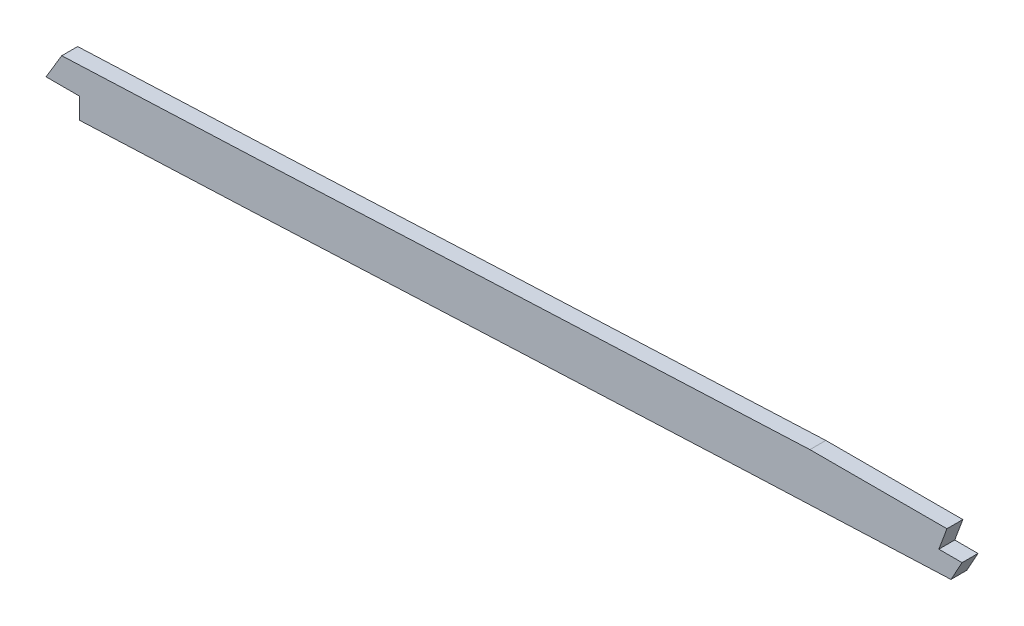
from build123d import *

# Parameters (mm, degrees)
BOSS_EXTRUDE1_DEPTH = 3.175
CUT_EXTRUDE1_DEPTH  = 7.3500001
FILLET1_R           = 2.54
CUT_EXTRUDE2_DEPTH  = 7.62


with BuildPart() as part:
    # Sketch1 → Boss-Extrude1 (new body, symmetric)
    with BuildSketch(Plane.XY):
        with BuildLine():
            Line((499.61002795, -53.470702797), (1046.28548189, -53.470702797))
            add(Edge.make_bspline(
                [(2669.54, -9.569049356), (2615.393603553, -13.17073937), (2561.080658619, -16.536108081), (2506.205230446, -19.758621957), (2430.209106802, -23.505211705), (2354.212983157, -26.631486423), (2332.570330468, -27.480988169), (2156.268639429, -34.377768543), (1979.966947376, -41.628631248), (1824.114277635, -52.771265877), (1636.928606778, -53.579569849), (1449.742935921, -53.454024613), (1418.006730935, -53.470702797), (1324.899336146, -53.470702797), (1231.791940344, -53.470702797), (1170.441269319, -53.470702797), (1108.784075813, -53.470702797), (1047.126882346, -53.470702797), (1046.846414188, -53.470702797), (1046.565947184, -53.470702797), (1046.28548189, -53.470702797)],
                knots=[103.698913506, 103.698913506, 103.698913506, 103.698913506, 103.698913506, 103.698913506, 130.927896619, 130.927896619, 130.927896619, 141.337054719, 141.337054719, 141.337054719, 218.101815019, 218.101815019, 218.101815019, 233.772059419, 233.772059419, 233.772059419, 264.077723219, 264.077723219, 264.077723219, 264.2162088, 264.2162088, 264.2162088, 264.2162088, 264.2162088, 264.2162088], degree=5))
            Line((2669.54, -9.569049356), (2669.54, 9.5231025))
            add(Edge.make_bspline(
                [(2669.54, 9.5231025), (2667.126494524, 9.36235515), (2659.861586685, 8.880281494), (2635.666282302, 7.292469146), (2596.857665529, 4.826056853), (2545.729743039, 1.758344093), (2494.405305707, -1.098555235), (2451.533022267, -3.266573297), (2417.198316756, -4.86708361), (2391.457076919, -6.003589235), (2365.634736307, -7.086854581), (2339.546284672, -8.137729944), (2313.466132974, -9.165138371), (2287.612375486, -10.179478215), (2261.763347437, -11.201032297), (2227.285329715, -12.583842557), (2184.175569393, -14.36607236), (2132.429066114, -16.607427868), (2063.4255234, -19.708920485), (1977.174907635, -23.700543313), (1873.732451432, -28.149389221), (1770.37461881, -31.657468649), (1667.085687813, -33.793117556), (1581.011094491, -34.383188831), (1512.07397126, -34.4278026), (1443.061513477, -34.409510402), (1356.800927879, -34.424432812), (1218.794626954, -34.418464788), (1115.289022786, -34.420702797), (1046.28548189, -34.420702797)],
                knots=[103.571582669, 103.571582669, 103.571582669, 103.571582669, 104.300777207, 105.766098403, 110.877392287, 115.98868617, 121.099980054, 126.211273938, 128.76692088, 131.322567822, 133.878214764, 136.433861706, 138.989508647, 141.545155589, 144.100802531, 146.656449473, 151.767743357, 156.879037241, 161.990331124, 172.212918892, 182.43550666, 192.658094427, 202.880682195, 213.103269962, 218.214563846, 223.32585773, 233.548445497, 243.771033265, 264.2162088, 264.2162088, 264.2162088, 264.2162088], degree=3))
            Line((1046.28548189, -34.420702797), (499.61002795, -34.420702797))
            add(Edge.make_bspline(
                [(499.61002795, -34.420702797), (488.614737518, -34.420702797), (472.236395365, -34.420702798), (449.940231846, -34.420702794), (427.771305695, -34.42070281), (405.874681663, -34.420702712), (384.584909128, -34.420702942), (368.900229326, -34.420702244), (353.376568613, -34.420704862), (332.608466435, -34.420689186), (306.287754853, -34.420570006), (274.023487704, -34.420538256), (252.271015965, -34.420709741), (241.425150134, -34.420702761)],
                knots=[19.90682951, 19.90682951, 19.90682951, 19.90682951, 23.220120017, 24.876765271, 26.533410525, 29.846701033, 31.503346286, 33.15999154, 34.816636794, 36.473282048, 39.786572556, 43.099863063, 46.413153571, 46.413153571, 46.413153571, 46.413153571], degree=3))
            add(Edge.make_bspline(
                [(241.425150134, -34.420702761), (239.394928853, -34.420701455), (235.322322927, -34.420495867), (227.274423443, -34.398702533), (217.319360062, -34.297466855), (205.530690077, -33.976385563), (189.963341914, -33.212641271), (170.696984653, -31.543495194), (147.533261232, -28.314398128), (125.482753206, -24.202109872), (109.358914834, -20.622537553), (100.964116069, -18.612521054), (99.06, -18.149327722)],
                knots=[0, 0, 0, 0, 0.622088422, 1.244176844, 2.488353689, 3.732530533, 4.976707377, 7.465061066, 9.953414755, 12.441768444, 14.55823542, 15.180323842, 15.180323842, 15.180323842, 15.180323842], degree=3))
            Line((99.06, -18.149327722), (99.06, -37.741485304))
            add(Edge.make_bspline(
                [(241.425137875, -53.470702761), (224.286916993, -53.470691732), (207.149474967, -53.467315374), (190.203897513, -52.686577078), (161.734965878, -49.987457476), (133.266034188, -45.175583375), (121.749620566, -42.910592695), (110.349390726, -40.420274627), (99.06, -37.741485304)],
                knots=[0, 0, 0, 0, 0, 0, 8.71381608, 8.71381608, 8.71381608, 14.701907176, 14.701907176, 14.701907176, 14.701907176, 14.701907176, 14.701907176], degree=5))
            add(Edge.make_bspline(
                [(499.61002795, -53.470702797), (492.136820835, -53.470702797), (484.754348064, -53.470702797), (477.443025859, -53.470702797), (448.516583145, -53.470702797), (419.590140517, -53.470702797), (398.368118521, -53.470702797), (355.647540186, -53.470702797), (312.926961851, -53.470702797), (289.235090436, -53.470293029), (265.364963651, -53.470705034), (241.4948369, -53.470702789), (241.471603891, -53.470702785), (241.448370882, -53.470702776), (241.425137875, -53.470702761)],
                knots=[19.90682951, 19.90682951, 19.90682951, 19.90682951, 19.90682951, 19.90682951, 23.637897311, 23.637897311, 23.637897311, 34.276545571, 34.276545571, 34.276545571, 46.401340901, 46.401340901, 46.401340901, 46.413153571, 46.413153571, 46.413153571, 46.413153571, 46.413153571, 46.413153571], degree=5))
        make_face()
    extrude(amount=BOSS_EXTRUDE1_DEPTH, both=True)

    # Sketch2 → Cut-Extrude1 (cut, through all)
    with BuildSketch(Plane.XY.offset(3.175)):
        with BuildLine():
            add(Edge.make_bspline(
                [(2312.9875, -9.183260037), (2304.505441691, -9.516700376), (2287.441020622, -10.186250162), (2261.763347437, -11.201032297), (2228.230552004, -12.545932515), (2203.310445107, -13.575047161), (2187.00995947, -14.263260037)],
                knots=[139.04033329, 139.04033329, 139.04033329, 139.04033329, 141.545155589, 144.100802531, 146.656449473, 151.487488909, 151.487488909, 151.487488909, 151.487488909], degree=3))
            Line((2187.00995947, -14.263260037), (2312.9875, -14.263260037))
            Line((2312.9875, -14.263260037), (2312.9875, -9.183260037))
        make_face()
    extrude(amount=-CUT_EXTRUDE1_DEPTH, mode=Mode.SUBTRACT)

    # Fillet1
    fillet1_edges = [part.edges().sort_by_distance(p)[0] for p in [
        (2669.54, -9.569049356, -1.5875),
        (2669.54, 9.5231025, -1.5875),
        (99.06, -37.741485304, -1.5875),
        (99.06, -18.149327722, -1.5875),
        (2312.9875, -9.183260037, 1.5875),
        (2312.9875, -14.263260037, 0),
    ]]
    fillet(fillet1_edges, radius=FILLET1_R)

    # Sketch3 → Cut-Extrude2 (cut)
    with BuildSketch(Plane.XY.offset(3.175)):
        Polygon((1888.274985361, -27.424617015), (1881.98614013, -37.858137115), (1895.406326502, -37.858137115), (1895.406326502, -46.204944132), (1895.406326502, -50.216890409), (-62.255721057, -449.759899711), (-121.19134177, 139.596307418), (1888.274985361, -1.80721617), align=None)
        Polygon((2241.72424439, -14.263260032), (2238.495432608, -22.960040401), (2247.777444945, -22.960040401), (2243.337690155, -31.006850231), (2243.337690155, -37.858137115), (2717.854896536, -90.640248849), (2717.854896536, 35.478991246), (2241.72424439, 2.049936484), align=None)
    extrude(amount=-CUT_EXTRUDE2_DEPTH, mode=Mode.SUBTRACT)


solid = part.part
